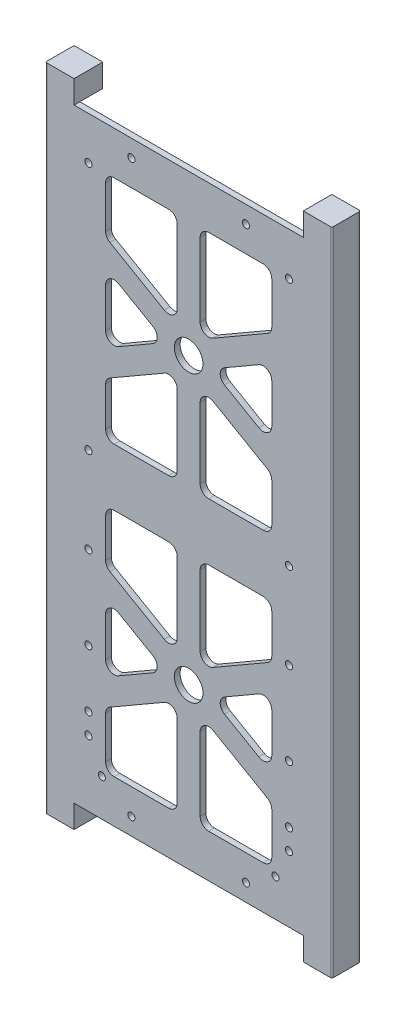
from build123d import *

# Parameters (mm, degrees)
SKETCH1_W                      = 88
SKETCH1_H                      = 211
BOSS_EXTRUDE1_DEPTH            = 2
CUT_EXTRUDE2_DEPTH             = 2
SKETCH4_R                      = 5
CUT_EXTRUDE3_DEPTH             = 3
FILLET2_R                      = 3
BOSS_EXTRUDE2_DEPTH            = 10
CUT_EXTRUDE5_DEPTH             = 8
M3X0_5_TAPPED_HOLE1_AT_2_COUNT = 2
M3X0_5_TAPPED_HOLE1_AT_2_PITCH = 30
M3X0_5_TAPPED_HOLE1_AT_3_COUNT = 2
M3X0_5_TAPPED_HOLE1_AT_3_PITCH = 59
M3X0_5_TAPPED_HOLE1_AT_4_COUNT = 2
M3X0_5_TAPPED_HOLE1_AT_4_PITCH = 79
M3X0_5_TAPPED_HOLE1_AT_5_COUNT = 2
M3X0_5_TAPPED_HOLE1_AT_5_PITCH = 96.314744458
M3X0_5_TAPPED_HOLE1_AT_6_COUNT = 2
M3X0_5_TAPPED_HOLE1_AT_6_PITCH = 96.967210953
M3X0_5_TAPPED_HOLE1_AT_7_COUNT = 2
M3X0_5_TAPPED_HOLE1_AT_7_PITCH = 104.284418779
M3X0_5_TAPPED_HOLE1_AT_8_COUNT = 2
M3X0_5_TAPPED_HOLE1_AT_8_PITCH = 86.2
M3X0_5_TAPPED_HOLE1_AT_9_COUNT = 2
M3X0_5_TAPPED_HOLE1_AT_9_PITCH = 86.8
SKETCH58_R                     = 1.665
CUT_EXTRUDE9_DEPTH             = 1.8
SKETCH59_R                     = 2
CUT_EXTRUDE10_DEPTH            = 10
FILLET3_R                      = 0.5


with BuildPart() as part:
    # Sketch1 → Boss-Extrude1 (new body)
    with BuildSketch(Plane.XY):
        with Locations((44, 105.5)):
            Rectangle(SKETCH1_W, SKETCH1_H)
    extrude(amount=BOSS_EXTRUDE1_DEPTH)

    # Sketch3 → Cut-Extrude2 (cut)
    with BuildSketch(Plane.XY.offset(2)):
        Polygon((73, 115.5), (73, 133.88804004), (48, 148.32179677), (48, 115.5), align=None)
        Polygon((40, 148.32179677), (15, 133.88804004), (15, 115.5), (40, 115.5), align=None)
        Polygon((36, 155.25), (15, 167.374355653), (15, 143.125644347), align=None)
        Polygon((73, 143.125644347), (73, 167.374355653), (52, 155.25), align=None)
        Polygon((73, 196), (48, 196), (48, 162.17820323), (73, 176.61195996), align=None)
        Polygon((40, 196), (15, 196), (15, 176.61195996), (40, 162.17820323), align=None)
    cut_extrude2 = extrude(amount=-CUT_EXTRUDE2_DEPTH, mode=Mode.SUBTRACT)

    # Sketch4 → Cut-Extrude3 (cut, through all)
    with BuildSketch(Plane.XY.offset(2)):
        with Locations((44, 155.25)):
            Circle(SKETCH4_R)
    cut_extrude3 = extrude(amount=-CUT_EXTRUDE3_DEPTH, mode=Mode.SUBTRACT)

    # Mirror2: Cut-Extrude2, Cut-Extrude3 across plane
    add(cut_extrude2.mirror(Plane(origin=(0, 105.5, 0), x_dir=(0, 0, 1), z_dir=(0, -1, 0))), mode=Mode.SUBTRACT)
    add(cut_extrude3.mirror(Plane(origin=(0, 105.5, 0), x_dir=(0, 0, 1), z_dir=(0, -1, 0))), mode=Mode.SUBTRACT)

    # Fillet2
    fillet2_edges = [part.edges().sort_by_distance(p)[0] for p in [
        (36, 55.75, 1),
        (15, 43.625644347, 1),
        (15, 67.874355653, 1),
        (40, 95.5, 1),
        (40, 62.67820323, 1),
        (15, 77.11195996, 1),
        (15, 95.5, 1),
        (48, 48.82179677, 1),
        (73, 34.38804004, 1),
        (73, 15, 1),
        (48, 15, 1),
        (73, 43.625644347, 1),
        (52, 55.75, 1),
        (73, 67.874355653, 1),
        (15, 15, 1),
        (15, 34.38804004, 1),
        (40, 48.82179677, 1),
        (40, 15, 1),
        (73, 77.11195996, 1),
        (48, 62.67820323, 1),
        (48, 95.5, 1),
        (73, 95.5, 1),
        (15, 167.374355653, 1),
        (36, 155.25, 1),
        (15, 143.125644347, 1),
        (40, 148.32179677, 1),
        (40, 115.5, 1),
        (15, 115.5, 1),
        (15, 133.88804004, 1),
        (73, 176.61195996, 1),
        (48, 162.17820323, 1),
        (48, 196, 1),
        (73, 196, 1),
        (52, 155.25, 1),
        (73, 167.374355653, 1),
        (73, 143.125644347, 1),
        (15, 176.61195996, 1),
        (15, 196, 1),
        (40, 196, 1),
        (40, 162.17820323, 1),
        (48, 148.32179677, 1),
        (73, 133.88804004, 1),
        (73, 115.5, 1),
        (48, 115.5, 1),
    ]]
    fillet(fillet2_edges, radius=FILLET2_R)

    # Sketch7 → Boss-Extrude2 (add)
    with BuildSketch(Plane.XY.offset(2)):
        Polygon((94, 219), (84, 219), (84, 211), (88, 211), (88, 0), (84, 0), (84, -8), (94, -8), align=None)
        Polygon((-6, -8), (4, -8), (4, 0), (0, 0), (0, 211), (4, 211), (4, 219), (-6, 219), align=None)
    extrude(amount=-BOSS_EXTRUDE2_DEPTH)

    # Sketch53 → Cut-Extrude5 (cut)
    with BuildSketch(Plane(origin=(0, 0, -8), x_dir=(-1, 0, 0), z_dir=(0, 0, -1))):
        with BuildLine():
            Line((-90, 0), (-88, 0))
            Line((-88, 0), (-88, 211))
            Line((-88, 211), (-90, 211))
            ThreePointArc((-90, 211), (-91.414213562, 210.414213562), (-92, 209))
            Line((-92, 209), (-92, 2))
            ThreePointArc((-92, 2), (-91.414213562, 0.585786438), (-90, 0))
        make_face()
        with BuildLine():
            Line((2, 0), (-4, 0))
            Line((-4, 0), (-4, 211))
            Line((-4, 211), (2, 211))
            ThreePointArc((2, 211), (3.414213562, 210.414213562), (4, 209))
            Line((4, 209), (4, 2))
            ThreePointArc((4, 2), (3.414213562, 0.585786438), (2, 0))
        make_face()
    extrude(amount=-CUT_EXTRUDE5_DEPTH, mode=Mode.SUBTRACT)

    # Sketch56 → M3x0.5 Tapped Hole1 (revolve, cut)
    with BuildSketch(Plane(origin=(9, 109.2, 2), x_dir=(0, -1, 0), z_dir=(1, 0, 0))):
        Polygon((0, 0), (0, 10.751075774), (1.25, 10), (1.25, 0), align=None)
    m3x0_5_tapped_hole1 = revolve(axis=Axis((9, 109.2, 8.35), (0, 0, -1)), mode=Mode.SUBTRACT)

    # M3x0.5 Tapped Hole1 at 2: M3x0.5 Tapped Hole1 ×2
    with Locations(*[(0, -i * M3X0_5_TAPPED_HOLE1_AT_2_PITCH, 0) for i in range(1, M3X0_5_TAPPED_HOLE1_AT_2_COUNT)]):
        add(m3x0_5_tapped_hole1, mode=Mode.SUBTRACT)

    # M3x0.5 Tapped Hole1 at 3: M3x0.5 Tapped Hole1 ×2
    with Locations(*[(0, -i * M3X0_5_TAPPED_HOLE1_AT_3_PITCH, 0) for i in range(1, M3X0_5_TAPPED_HOLE1_AT_3_COUNT)]):
        add(m3x0_5_tapped_hole1, mode=Mode.SUBTRACT)

    # M3x0.5 Tapped Hole1 at 4: M3x0.5 Tapped Hole1 ×2
    with Locations(*[(0, -i * M3X0_5_TAPPED_HOLE1_AT_4_PITCH, 0) for i in range(1, M3X0_5_TAPPED_HOLE1_AT_4_COUNT)]):
        add(m3x0_5_tapped_hole1, mode=Mode.SUBTRACT)

    # M3x0.5 Tapped Hole1 at 5: M3x0.5 Tapped Hole1 ×2
    with Locations(*[Vector(0.048798344, -0.998808651, 0) * (i * M3X0_5_TAPPED_HOLE1_AT_5_PITCH) for i in range(1, M3X0_5_TAPPED_HOLE1_AT_5_COUNT)]):
        add(m3x0_5_tapped_hole1, mode=Mode.SUBTRACT)

    # M3x0.5 Tapped Hole1 at 6: M3x0.5 Tapped Hole1 ×2
    with Locations(*[Vector(0.154691466, 0.987962828, 0) * (i * M3X0_5_TAPPED_HOLE1_AT_6_PITCH) for i in range(1, M3X0_5_TAPPED_HOLE1_AT_6_COUNT)]):
        add(m3x0_5_tapped_hole1, mode=Mode.SUBTRACT)

    # M3x0.5 Tapped Hole1 at 7: M3x0.5 Tapped Hole1 ×2
    with Locations(*[Vector(0.143837403, -0.989601335, 0) * (i * M3X0_5_TAPPED_HOLE1_AT_7_PITCH) for i in range(1, M3X0_5_TAPPED_HOLE1_AT_7_COUNT)]):
        add(m3x0_5_tapped_hole1, mode=Mode.SUBTRACT)

    # M3x0.5 Tapped Hole1 at 8: M3x0.5 Tapped Hole1 ×2
    with Locations(*[(0, -i * M3X0_5_TAPPED_HOLE1_AT_8_PITCH, 0) for i in range(1, M3X0_5_TAPPED_HOLE1_AT_8_COUNT)]):
        add(m3x0_5_tapped_hole1, mode=Mode.SUBTRACT)

    # M3x0.5 Tapped Hole1 at 9: M3x0.5 Tapped Hole1 ×2
    with Locations(*[(0, i * M3X0_5_TAPPED_HOLE1_AT_9_PITCH, 0) for i in range(1, M3X0_5_TAPPED_HOLE1_AT_9_COUNT)]):
        add(m3x0_5_tapped_hole1, mode=Mode.SUBTRACT)

    # Mirror3: M3x0.5 Tapped Hole1 across plane
    add(m3x0_5_tapped_hole1.mirror(Plane.ZY.offset(-44)), mode=Mode.SUBTRACT)

    # Mirror3 copy 1 sketch → Mirror3 copy 1 (revolve, cut)
    with BuildSketch(Plane(origin=(79, 79.2, 2), x_dir=(0, -1, 0), z_dir=(-1, 0, 0))):
        Polygon((0, 0), (0, -10.751075774), (1.25, -10), (1.25, 0), align=None)
    revolve(axis=Axis((79, 79.2, 8.35), (0, 0, 1)), mode=Mode.SUBTRACT)

    # Mirror3 copy 2 sketch → Mirror3 copy 2 (revolve, cut)
    with BuildSketch(Plane(origin=(79, 50.2, 2), x_dir=(0, -1, 0), z_dir=(-1, 0, 0))):
        Polygon((0, 0), (0, -10.751075774), (1.25, -10), (1.25, 0), align=None)
    revolve(axis=Axis((79, 50.2, 8.35), (0, 0, 1)), mode=Mode.SUBTRACT)

    # Mirror3 copy 3 sketch → Mirror3 copy 3 (revolve, cut)
    with BuildSketch(Plane(origin=(79, 30.2, 2), x_dir=(0, -1, 0), z_dir=(-1, 0, 0))):
        Polygon((0, 0), (0, -10.751075774), (1.25, -10), (1.25, 0), align=None)
    revolve(axis=Axis((79, 30.2, 8.35), (0, 0, 1)), mode=Mode.SUBTRACT)

    # Mirror3 copy 4 sketch → Mirror3 copy 4 (revolve, cut)
    with BuildSketch(Plane(origin=(74.3, 13, 2), x_dir=(0, -1, 0), z_dir=(-1, 0, 0))):
        Polygon((0, 0), (0, -10.751075774), (1.25, -10), (1.25, 0), align=None)
    revolve(axis=Axis((74.3, 13, 8.35), (0, 0, 1)), mode=Mode.SUBTRACT)

    # Mirror3 copy 5 sketch → Mirror3 copy 5 (revolve, cut)
    with BuildSketch(Plane(origin=(64, 205, 2), x_dir=(0, -1, 0), z_dir=(-1, 0, 0))):
        Polygon((0, 0), (0, -10.751075774), (1.25, -10), (1.25, 0), align=None)
    revolve(axis=Axis((64, 205, 8.35), (0, 0, 1)), mode=Mode.SUBTRACT)

    # Mirror3 copy 6 sketch → Mirror3 copy 6 (revolve, cut)
    with BuildSketch(Plane(origin=(64, 6, 2), x_dir=(0, -1, 0), z_dir=(-1, 0, 0))):
        Polygon((0, 0), (0, -10.751075774), (1.25, -10), (1.25, 0), align=None)
    revolve(axis=Axis((64, 6, 8.35), (0, 0, 1)), mode=Mode.SUBTRACT)

    # Mirror3 copy 7 sketch → Mirror3 copy 7 (revolve, cut)
    with BuildSketch(Plane(origin=(79, 23, 2), x_dir=(0, -1, 0), z_dir=(-1, 0, 0))):
        Polygon((0, 0), (0, -10.751075774), (1.25, -10), (1.25, 0), align=None)
    revolve(axis=Axis((79, 23, 8.35), (0, 0, 1)), mode=Mode.SUBTRACT)

    # Mirror3 copy 8 sketch → Mirror3 copy 8 (revolve, cut)
    with BuildSketch(Plane(origin=(79, 196, 2), x_dir=(0, -1, 0), z_dir=(-1, 0, 0))):
        Polygon((0, 0), (0, -10.751075774), (1.25, -10), (1.25, 0), align=None)
    revolve(axis=Axis((79, 196, 8.35), (0, 0, 1)), mode=Mode.SUBTRACT)

    # Sketch58 → Cut-Extrude9 (cut)
    with BuildSketch(Plane(origin=(0, 0, 0), x_dir=(-1, 0, 0), z_dir=(0, 0, -1))):
        with Locations((-0.7, 13)):
            Circle(SKETCH58_R)
    cut_extrude9 = extrude(amount=-CUT_EXTRUDE9_DEPTH, mode=Mode.SUBTRACT)

    # Mirror4: Cut-Extrude9 across plane
    add(cut_extrude9.mirror(Plane(origin=(44, 0, 0), x_dir=(0, 0, 1), z_dir=(1, 0, 0))), mode=Mode.SUBTRACT)

    # Sketch59 → Cut-Extrude10 (cut)
    with BuildSketch(Plane(origin=(0, -8, 0), x_dir=(-1, 0, 0), z_dir=(0, -1, 0))):
        with Locations((-89, 2.4)):
            Circle(SKETCH59_R)
        with Locations((1, 2.4)):
            Circle(SKETCH59_R)
    extrude(amount=-CUT_EXTRUDE10_DEPTH, mode=Mode.SUBTRACT)

    # Fillet3
    fillet3_edges = [part.edges().sort_by_distance(p)[0] for p in [
        (94, 105.5, -8),
        (94, 105.5, 2),
        (-6, 105.5, -8),
        (-6, 105.5, 2),
    ]]
    fillet(fillet3_edges, radius=FILLET3_R)


solid = part.part
